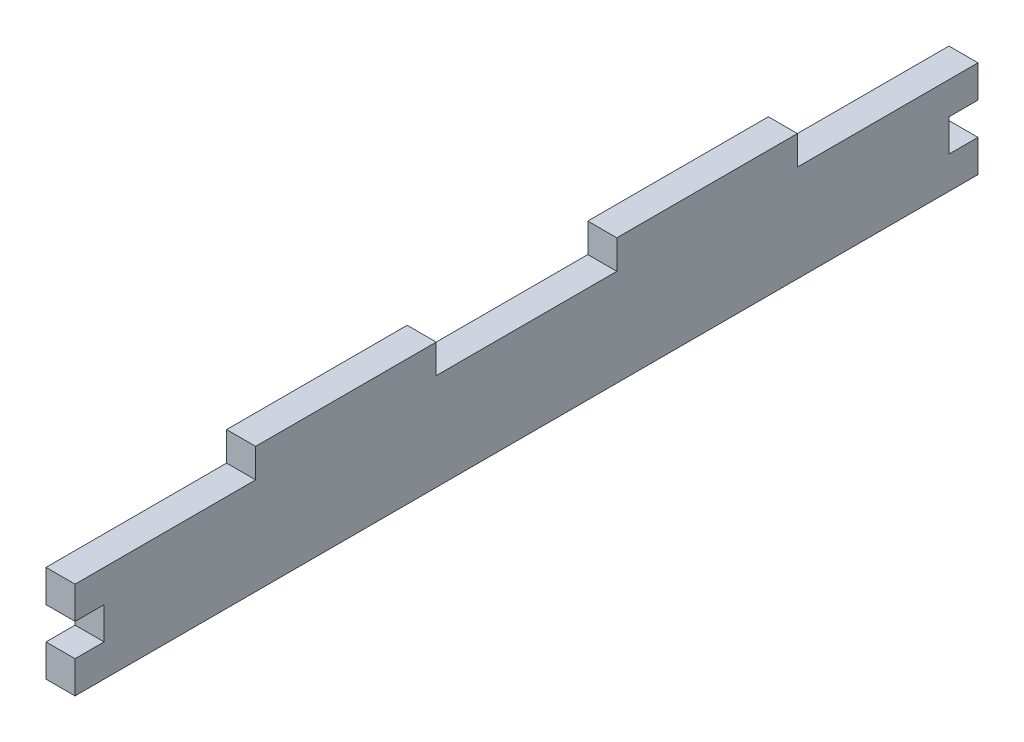
from build123d import *

# Parameters (mm, degrees)
SKETCH1_W               = 415
SKETCH1_H               = 126.5
BOSS_EXTRUDE1_DEPTH     = 6
SKETCH2_W               = 6
SKETCH2_H               = 186.5
BOSS_EXTRUDE2_DEPTH     = 20
CUT_EXTRUDE1_DEPTH      = 256.534366573
CUT_EXTRUDE1_DEPTH_BACK = 256.534366573
SKETCH1_2_W             = 415
SKETCH1_2_H             = 126.5
SKETCH2_4_W             = 6
SKETCH2_4_H             = 37.3
BOSS_EXTRUDE3_DEPTH     = 6
SKETCH5_W               = 6
SKETCH5_H               = 6.666666666
CUT_EXTRUDE3_DEPTH      = 6


with BuildPart() as part:
    # Sketch1 → Boss-Extrude1 (new body)
    with BuildSketch(Plane(origin=(0, 0, 0), x_dir=(1, 0, 0), z_dir=(0, 1, 0))):
        Rectangle(SKETCH1_W, SKETCH1_H)
    extrude(amount=BOSS_EXTRUDE1_DEPTH)

    # Sketch1_2 → Cut-Extrude1 (cut, two sides: drawn at the far end of the back side and taken through both)
    with BuildSketch(Plane(origin=(0, 0, 0), x_dir=(1, 0, 0), z_dir=(0, 1, 0)).offset(-CUT_EXTRUDE1_DEPTH_BACK)):
        Rectangle(SKETCH1_2_W, SKETCH1_2_H)
    extrude(amount=CUT_EXTRUDE1_DEPTH + CUT_EXTRUDE1_DEPTH_BACK, mode=Mode.SUBTRACT)


with BuildPart() as body_2:
    # Sketch2 → Boss-Extrude2 (new body)
    with BuildSketch(Plane(origin=(0, 6, 0), x_dir=(1, 0, 0), z_dir=(0, 1, 0))):
        with Locations((-234.5, 0)):
            Rectangle(SKETCH2_W, SKETCH2_H)
    extrude(amount=-BOSS_EXTRUDE2_DEPTH)

    # Sketch2_4 → Boss-Extrude3 (add)
    with BuildSketch(Plane(origin=(0, 6, 0), x_dir=(1, 0, 0), z_dir=(0, 1, 0))):
        with Locations((-234.5, -37.3)):
            Rectangle(SKETCH2_4_W, SKETCH2_4_H)
        with Locations((-234.5, 37.3)):
            Rectangle(SKETCH2_4_W, SKETCH2_4_H)
    extrude(amount=BOSS_EXTRUDE3_DEPTH)

    # Sketch5 → Cut-Extrude3 (cut)
    with BuildSketch(Plane.XY.offset(93.25)):
        with Locations((-234.5, -4)):
            Rectangle(SKETCH5_W, SKETCH5_H)
    cut_extrude3 = extrude(amount=-CUT_EXTRUDE3_DEPTH, mode=Mode.SUBTRACT)

    # Mirror3: Cut-Extrude3 across plane
    add(cut_extrude3.mirror(Plane.XY), mode=Mode.SUBTRACT)


solid = body_2.part
